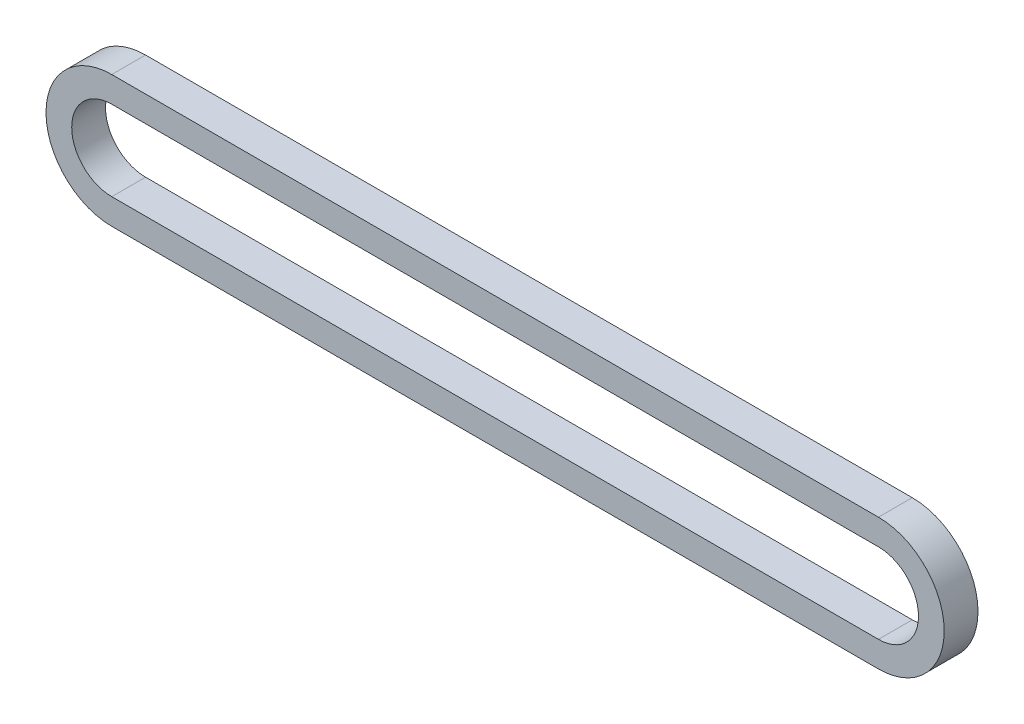
from build123d import *

# Parameters (mm, degrees)
EXTRUDE_THIN1_DEPTH = 5.8801


with BuildPart() as part:
    # Sketch1 → Extrude-Thin1 (new body, symmetric)
    with BuildSketch(Plane.XY):
        with BuildLine():
            Line((266.7, -22.871286991), (0, -22.871286991))
            ThreePointArc((0, -22.871286991), (-22.871286991, 0), (0, 22.871286991))
            Line((0, 22.871286991), (266.7, 22.871286991))
            ThreePointArc((266.7, 22.871286991), (289.571286991, 0), (266.7, -22.871286991))
        make_face()
        with BuildLine():
            Line((266.7, -13.930486991), (0, -13.930486991))
            ThreePointArc((0, -13.930486991), (-13.930486991, 0), (0, 13.930486991))
            Line((0, 13.930486991), (266.7, 13.930486991))
            ThreePointArc((266.7, 13.930486991), (280.630486991, 0), (266.7, -13.930486991))
        make_face(mode=Mode.SUBTRACT)
    extrude(amount=EXTRUDE_THIN1_DEPTH, both=True)


solid = part.part
